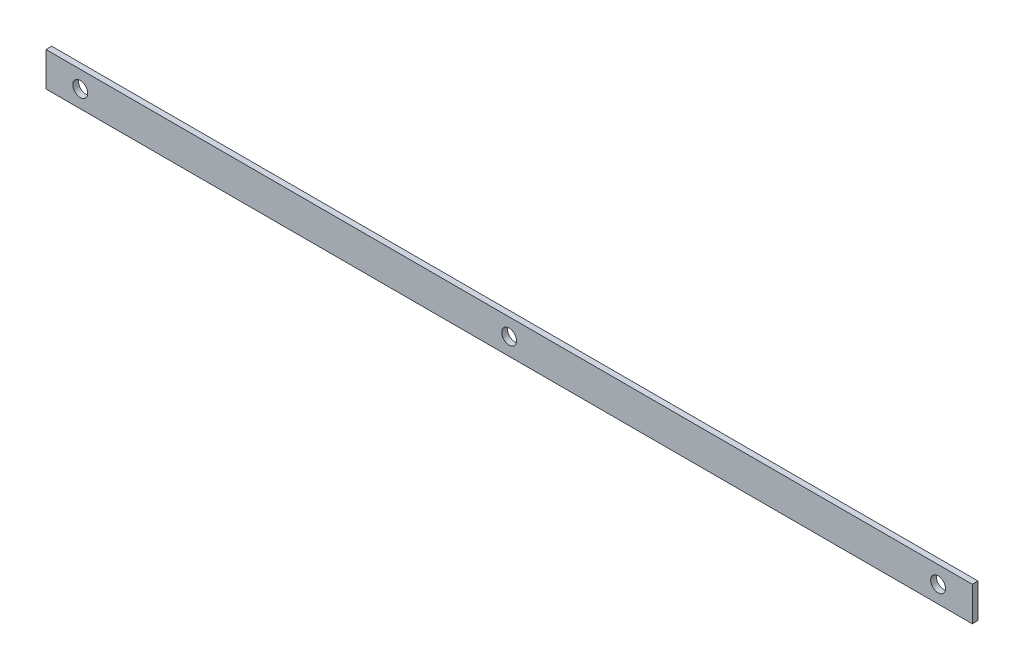
from build123d import *

# Parameters (mm, degrees)
PLAT_W                          = 30
PLAT_H                          = 5
EL_MENT_M_CANO_SOUD_1_DEPTH     = 812
DIAM_TRE_DU_PER_AGE_13_0_13_1_D = 13
R_P_TITION_LIN_AIRE2_COUNT      = 3
R_P_TITION_LIN_AIRE2_PITCH      = 376


with BuildPart() as part:
    # plat → Elément mécano-soudé1 (new body)
    with BuildSketch(Plane.YZ.offset(-406)):
        Rectangle(PLAT_W, PLAT_H)
    extrude(amount=EL_MENT_M_CANO_SOUD_1_DEPTH)

    # Diamètre du perçage Ø13.0 (13)1 (through all)
    with Locations(Plane(origin=(0, 0, -2.5), x_dir=(-1, 0, 0), z_dir=(0, 0, -1))):
        with Locations((376, 0)):
            diam_tre_du_per_age_13_0_13_1 = Hole(DIAM_TRE_DU_PER_AGE_13_0_13_1_D / 2)

    # Répétition linéaire2: Diamètre du perçage Ø13.0 (13)1 ×3
    with Locations(*[(i * R_P_TITION_LIN_AIRE2_PITCH, 0, 0) for i in range(1, R_P_TITION_LIN_AIRE2_COUNT)]):
        add(diam_tre_du_per_age_13_0_13_1, mode=Mode.SUBTRACT)


solid = part.part
